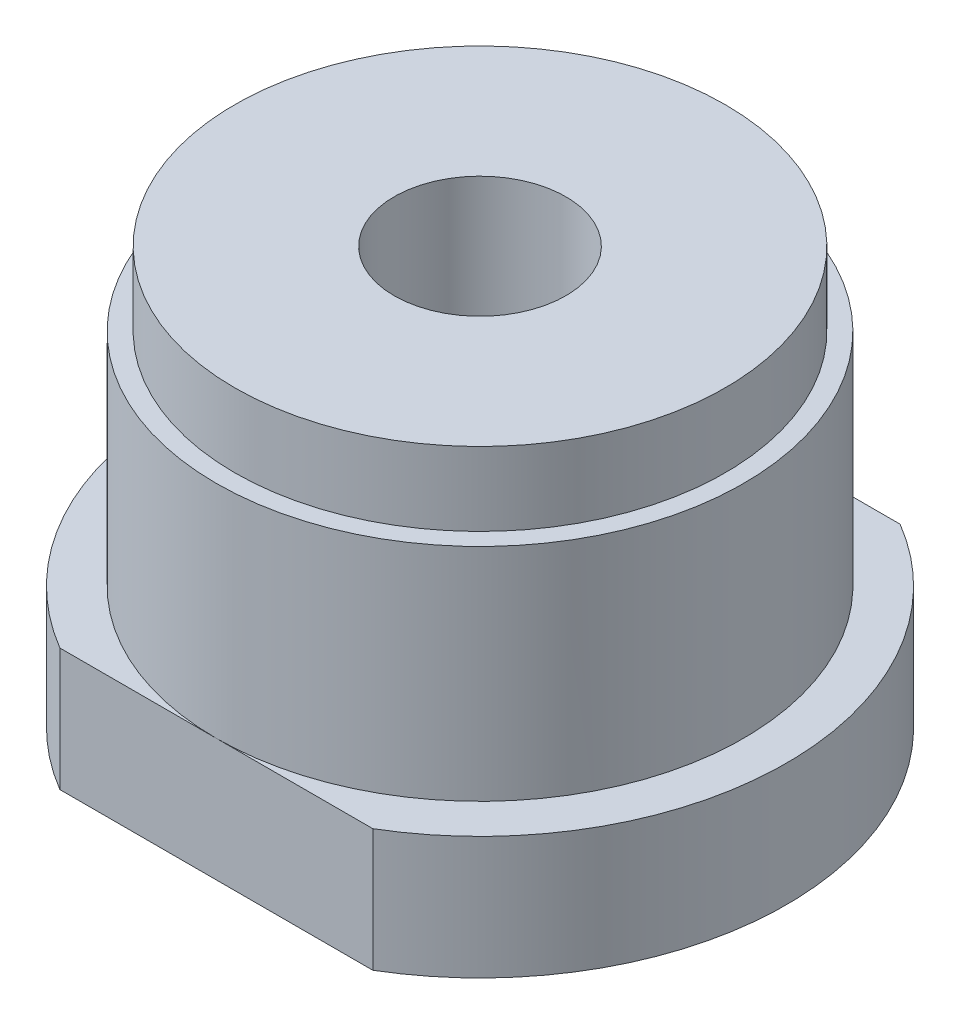
from build123d import *

# Parameters (mm, degrees)
SKETCH1_R           = 12.5
BOSS_EXTRUDE1_DEPTH = 17
SKETCH2_R           = 3.5
CUT_EXTRUDE1_DEPTH  = 15
SKETCH4_OUTSIDE_W   = 34.846
SKETCH4_OUTSIDE_H   = 34.846
SKETCH4_OUTSIDE_R   = 10
CUT_EXTRUDE3_DEPTH  = 12
SKETCH5_R           = 1.25
CUT_EXTRUDE4_DEPTH  = 10
SKETCH8_R           = 10.75
SKETCH8_R_2         = 4
BOSS_EXTRUDE3_DEPTH = 9
SKETCH7_W           = 22.925756412
SKETCH7_H           = 4.884412095
CUT_EXTRUDE6_DEPTH  = 6


with BuildPart() as part:
    # Sketch1 → Boss-Extrude1 (new body)
    with BuildSketch(Plane(origin=(0, 0, 0), x_dir=(1, 0, 0), z_dir=(0, 1, 0))):
        Circle(SKETCH1_R)
    extrude(amount=BOSS_EXTRUDE1_DEPTH)

    # Sketch2 → Cut-Extrude1 (cut)
    with BuildSketch(Plane(origin=(0, 17, 0), x_dir=(1, 0, 0), z_dir=(0, 1, 0))):
        Circle(SKETCH2_R)
    extrude(amount=-CUT_EXTRUDE1_DEPTH, mode=Mode.SUBTRACT)

    # Sketch4 outside → Cut-Extrude3 (cut)
    with BuildSketch(Plane(origin=(0, 17, 0), x_dir=(1, 0, 0), z_dir=(0, 1, 0))):
        Rectangle(SKETCH4_OUTSIDE_W, SKETCH4_OUTSIDE_H)
        Circle(SKETCH4_OUTSIDE_R, mode=Mode.SUBTRACT)
    extrude(amount=-CUT_EXTRUDE3_DEPTH, mode=Mode.SUBTRACT)

    # Sketch5 → Cut-Extrude4 (cut)
    with BuildSketch(Plane.XZ):
        with Locations((-8, 0)):
            Circle(SKETCH5_R)
    cut_extrude4 = extrude(amount=-CUT_EXTRUDE4_DEPTH, mode=Mode.SUBTRACT)

    # Mirror2: Cut-Extrude4 across plane
    add(cut_extrude4.mirror(Plane(origin=(0, 0, 0), x_dir=(0, 0, 1), z_dir=(1, 0, 0))), mode=Mode.SUBTRACT)

    # Sketch8 → Boss-Extrude3 (add)
    with BuildSketch(Plane(origin=(0, 5, 0), x_dir=(1, 0, 0), z_dir=(0, 1, 0))):
        Circle(SKETCH8_R)
        Circle(SKETCH8_R_2, mode=Mode.SUBTRACT)
    extrude(amount=BOSS_EXTRUDE3_DEPTH)

    # Sketch7 → Cut-Extrude6 (cut, through all)
    with BuildSketch(Plane(origin=(0, 5, 0), x_dir=(1, 0, 0), z_dir=(0, 1, 0))):
        with Locations((0.376120232, 13.192206048)):
            Rectangle(SKETCH7_W, SKETCH7_H)
    cut_extrude6 = extrude(amount=-CUT_EXTRUDE6_DEPTH, mode=Mode.SUBTRACT)

    # Mirror3: Cut-Extrude6 across plane
    add(cut_extrude6.mirror(Plane.XY), mode=Mode.SUBTRACT)


solid = part.part
